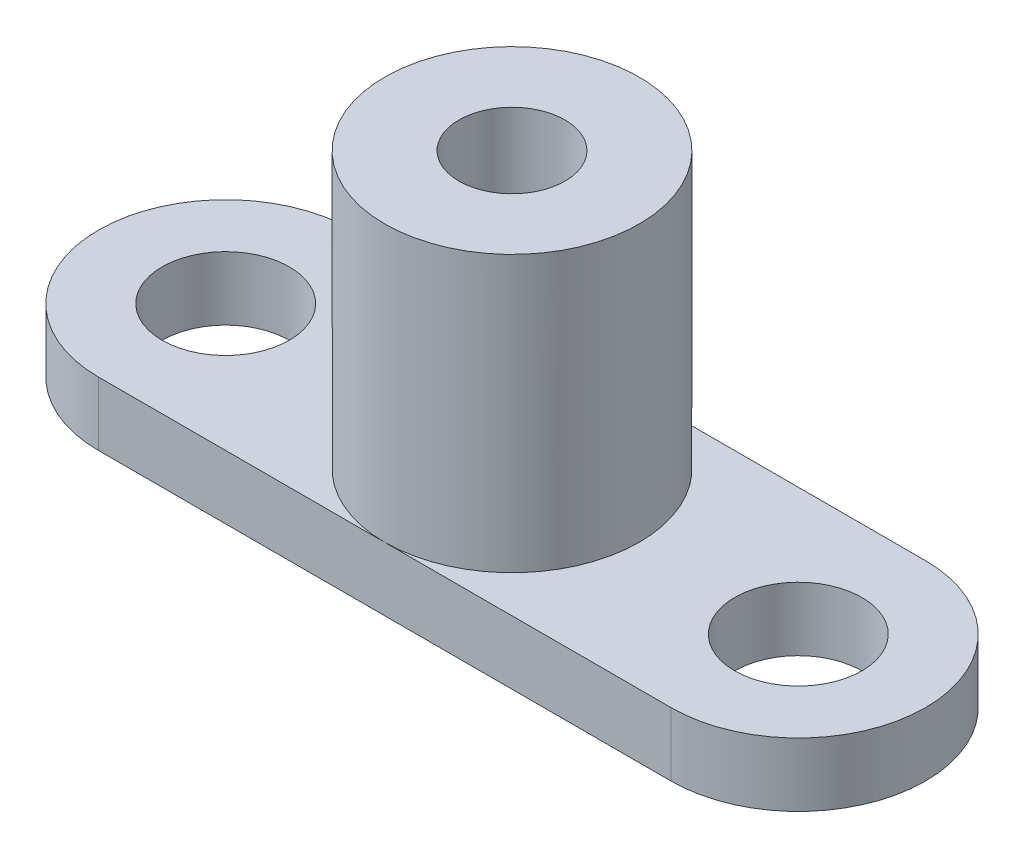
from build123d import *

# Parameters (mm, degrees)
SKETCH_1_R             = 6
EXTRUDE_1_DEPTH        = 3
SKETCH_2_R             = 6
EXTRUDE_2_DEPTH        = 13
HOLE_WIZARD_M6_1_D     = 5
HOLE_WIZARD_M6_1_DEPTH = 12
HOLE_WIZARD_M6_1_TIP   = 1.502151548
SKETCH_6_R             = 3
CUT_EXTRUDE_1_DEPTH    = 10


with BuildPart() as part:
    # 草图1 → 凸台-拉伸1 (new body)
    with BuildSketch(Plane(origin=(0, 0, 0), x_dir=(1, 0, 0), z_dir=(0, 1, 0))):
        with Locations((-13.5, 0)):
            Circle(SKETCH_1_R)
        with BuildLine():
            Line((13.5, 6), (-13.5, 6))
            ThreePointArc((-13.5, 6), (-9.257359313, 4.242640687), (-7.5, 0))
            ThreePointArc((-7.5, 0), (-9.257359313, -4.242640687), (-13.5, -6))
            Line((-13.5, -6), (13.5, -6))
            ThreePointArc((13.5, -6), (7.5, 0), (13.5, 6))
        make_face()
        with Locations((13.5, 0)):
            Circle(SKETCH_1_R)
        with BuildLine():
            Line((-13.5, -6), (-13.5, 6))
            ThreePointArc((-13.5, 6), (-19.5, 0), (-13.5, -6))
        make_face()
        with BuildLine():
            ThreePointArc((19.5, 0), (17.742640687, 4.242640687), (13.5, 6))
            Line((13.5, 6), (13.5, -6))
            ThreePointArc((13.5, -6), (17.742640687, -4.242640687), (19.5, 0))
        make_face()
    extrude(amount=EXTRUDE_1_DEPTH)

    # 草图2 → 凸台-拉伸2 (add)
    with BuildSketch(Plane(origin=(0, 3, 0), x_dir=(1, 0, 0), z_dir=(0, 1, 0))):
        Circle(SKETCH_2_R)
    extrude(amount=EXTRUDE_2_DEPTH)

    # M6 螺纹孔1
    with Locations(Plane(origin=(0, 16, 0), x_dir=(1, 0, 0), z_dir=(0, 1, 0))):
        with Locations((0, 0)):
            Hole(HOLE_WIZARD_M6_1_D / 2, depth=HOLE_WIZARD_M6_1_DEPTH)
            with Locations((0, 0, -(HOLE_WIZARD_M6_1_DEPTH + HOLE_WIZARD_M6_1_TIP / 2))):  # 118° drill point
                Cone(0, HOLE_WIZARD_M6_1_D / 2, HOLE_WIZARD_M6_1_TIP, mode=Mode.SUBTRACT)

    # 草图6 → 切除-拉伸1 (cut)
    with BuildSketch(Plane(origin=(0, 3, 0), x_dir=(1, 0, 0), z_dir=(0, 1, 0))):
        with Locations((-13.5, 0)):
            Circle(SKETCH_6_R)
        with Locations((13.5, 0)):
            Circle(SKETCH_6_R)
    extrude(amount=-CUT_EXTRUDE_1_DEPTH, mode=Mode.SUBTRACT)


solid = part.part
